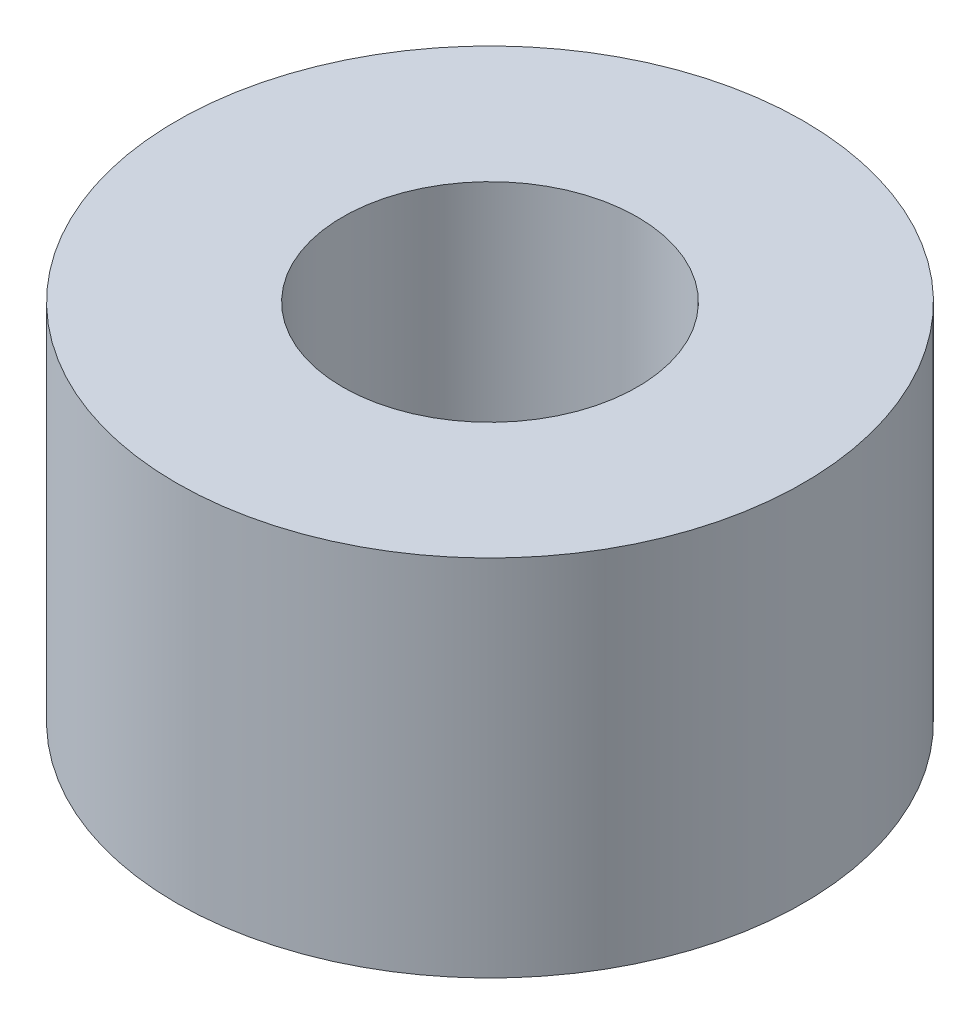
from build123d import *

# Parameters (mm, degrees)
SKETCH1_R           = 2.5
SKETCH1_R_2         = 1.175
BOSS_EXTRUDE1_DEPTH = 2.9


with BuildPart() as part:
    # Sketch1 → Boss-Extrude1 (new body)
    with BuildSketch(Plane(origin=(0, 0, 0), x_dir=(1, 0, 0), z_dir=(0, 1, 0))):
        Circle(SKETCH1_R)
        Circle(SKETCH1_R_2, mode=Mode.SUBTRACT)
    extrude(amount=BOSS_EXTRUDE1_DEPTH)


solid = part.part
